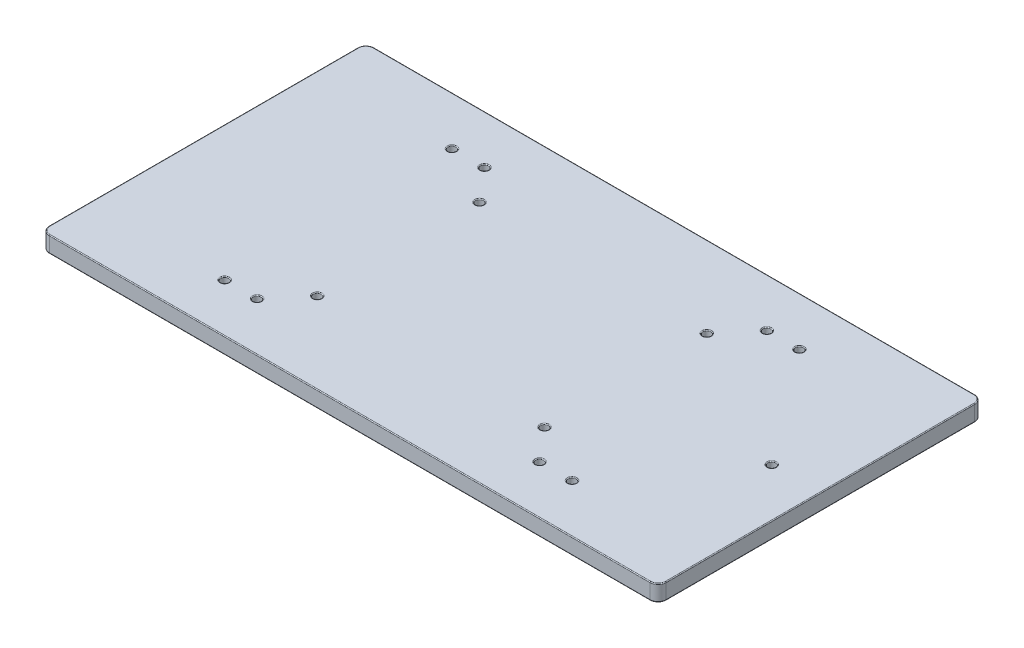
from build123d import *

# Parameters (mm, degrees)
SKETCH1_W           = 190
SKETCH1_H           = 100
SKETCH1_R           = 1.25
BOSS_EXTRUDE1_DEPTH = 5
FILLET1_R           = 2.5
FILLET2_R           = 0.25


with BuildPart() as part:
    # Sketch1 → Boss-Extrude1 (new body)
    with BuildSketch(Plane(origin=(0, 0, 0), x_dir=(1, 0, 0), z_dir=(0, 1, 0))):
        Rectangle(SKETCH1_W, SKETCH1_H)
        with Locations((-35, 25)):
            Circle(SKETCH1_R, mode=Mode.SUBTRACT)
        with Locations((35, 25)):
            Circle(SKETCH1_R, mode=Mode.SUBTRACT)
        with Locations((35, -25)):
            Circle(SKETCH1_R, mode=Mode.SUBTRACT)
        with Locations((-35, -25)):
            Circle(SKETCH1_R, mode=Mode.SUBTRACT)
        with Locations((80, 0)):
            Circle(SKETCH1_R, mode=Mode.SUBTRACT)
        with Locations((-53.5, -35)):
            Circle(SKETCH1_R, mode=Mode.SUBTRACT)
        with Locations((-43.5, -35)):
            Circle(SKETCH1_R, mode=Mode.SUBTRACT)
        with Locations((-53.5, 35)):
            Circle(SKETCH1_R, mode=Mode.SUBTRACT)
        with Locations((-43.5, 35)):
            Circle(SKETCH1_R, mode=Mode.SUBTRACT)
        with Locations((53.5, -35)):
            Circle(SKETCH1_R, mode=Mode.SUBTRACT)
        with Locations((43.5, -35)):
            Circle(SKETCH1_R, mode=Mode.SUBTRACT)
        with Locations((53.5, 35)):
            Circle(SKETCH1_R, mode=Mode.SUBTRACT)
        with Locations((43.5, 35)):
            Circle(SKETCH1_R, mode=Mode.SUBTRACT)
    extrude(amount=BOSS_EXTRUDE1_DEPTH)

    # Fillet1
    fillet1_edges = [part.edges().sort_by_distance(p)[0] for p in [
        (95, 2.5, 50),
        (-95, 2.5, 50),
        (-95, 2.5, -50),
        (95, 2.5, -50),
    ]]
    fillet(fillet1_edges, radius=FILLET1_R)

    # Fillet2
    fillet2_edges = [part.edges().sort_by_distance(p)[0] for p in [
        (-36.25, 0, -25),
        (-36.25, 5, -25),
        (33.75, 0, -25),
        (33.75, 5, -25),
        (33.75, 0, 25),
        (33.75, 5, 25),
        (-36.25, 0, 25),
        (-36.25, 5, 25),
        (78.75, 0, 0),
        (78.75, 5, 0),
        (-54.75, 0, 35),
        (-54.75, 5, 35),
        (-44.75, 0, 35),
        (-44.75, 5, 35),
        (-54.75, 0, -35),
        (-54.75, 5, -35),
        (-44.75, 0, -35),
        (-44.75, 5, -35),
        (52.25, 0, 35),
        (52.25, 5, 35),
        (42.25, 0, 35),
        (42.25, 5, 35),
        (52.25, 0, -35),
        (52.25, 5, -35),
        (42.25, 0, -35),
        (42.25, 5, -35),
        (-95, 0, 0),
        (-95, 5, 0),
        (95, 0, 0),
        (0, 0, 50),
        (0, 0, -50),
        (94.267766953, 0, 49.267766953),
        (94.267766953, 0, -49.267766953),
        (-94.267766953, 0, 49.267766953),
        (-94.267766953, 0, -49.267766953),
        (0, 5, -50),
        (95, 5, 0),
        (0, 5, 50),
        (94.267766953, 5, 49.267766953),
        (94.267766953, 5, -49.267766953),
        (-94.267766953, 5, 49.267766953),
        (-94.267766953, 5, -49.267766953),
    ]]
    fillet(fillet2_edges, radius=FILLET2_R)


solid = part.part
